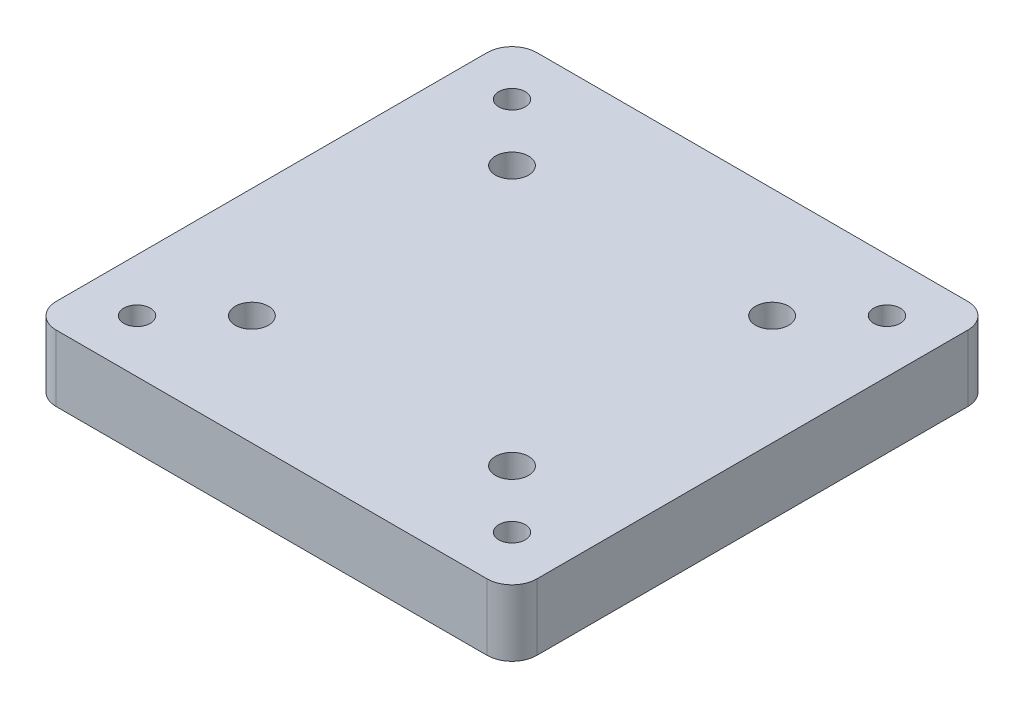
from build123d import *

# Parameters (mm, degrees)
SZKIC2_R                    = 1.6
SZKIC2_R_2                  = 1.598649761
SZKIC2_R_3                  = 1.598671199
SZKIC2_R_4                  = 2
DODANIE_WYCI_GNI_CIE1_DEPTH = 8
DODANIE_WYCI_GNI_CIE2_START = -2
SZKIC2_3_R                  = 6
SZKIC2_3_R_2                = 2
DODANIE_WYCI_GNI_CIE2_DEPTH = 2


with BuildPart() as part:
    # Szkic2 → Dodanie-wyci_gni_cie1 (new body)
    with BuildSketch(Plane(origin=(0, 0, 0), x_dir=(1, 0, 0), z_dir=(0, 1, 0))):
        with BuildLine():
            ThreePointArc((-79.341028527, -55.261863724), (-78.46234887, -57.383184068), (-76.341028527, -58.261863724))
            Line((-76.341028527, -58.261863724), (-24.341028527, -58.261863724))
            ThreePointArc((-24.341028527, -58.261863724), (-22.219708183, -57.383184068), (-21.341028527, -55.261863724))
            Line((-21.341028527, -55.261863724), (-21.341028527, -3.261863724))
            ThreePointArc((-21.341028527, -3.261863724), (-22.219708183, -1.140543381), (-24.341028527, -0.261863724))
            Line((-24.341028527, -0.261863724), (-76.341028527, -0.261863724))
            ThreePointArc((-76.341028527, -0.261863724), (-78.46234887, -1.140543381), (-79.341028527, -3.261863724))
            Line((-79.341028527, -3.261863724), (-79.341028527, -55.261863724))
        make_face()
        with Locations((-72.966028527, -51.886863724)):
            Circle(SZKIC2_R, mode=Mode.SUBTRACT)
        with Locations((-27.716028527, -51.886863724)):
            Circle(SZKIC2_R_2, mode=Mode.SUBTRACT)
        with Locations((-72.966028527, -6.636863724)):
            Circle(SZKIC2_R_3, mode=Mode.SUBTRACT)
        with Locations((-27.716028527, -6.636863724)):
            Circle(SZKIC2_R, mode=Mode.SUBTRACT)
        with Locations((-66.036028527, -44.956863724)):
            Circle(SZKIC2_R_4, mode=Mode.SUBTRACT)
        with Locations((-34.646028527, -44.956863724)):
            Circle(SZKIC2_R_4, mode=Mode.SUBTRACT)
        with Locations((-66.036028527, -13.566863724)):
            Circle(SZKIC2_R_4, mode=Mode.SUBTRACT)
        with Locations((-34.646028527, -13.566863724)):
            Circle(SZKIC2_R_4, mode=Mode.SUBTRACT)
    extrude(amount=DODANIE_WYCI_GNI_CIE1_DEPTH)

    # Szkic2_3 → Dodanie-wyci_gni_cie2 (add)
    # profile 1 of 4: a face of its own
    with BuildSketch(Plane(origin=(0, 0, 0), x_dir=(1, 0, 0), z_dir=(0, 1, 0)).offset(DODANIE_WYCI_GNI_CIE2_START)):
        with Locations((-66.036028527, -13.566863724)):
            Circle(SZKIC2_3_R)
        with Locations((-66.036028527, -13.566863724)):
            Circle(SZKIC2_3_R_2, mode=Mode.SUBTRACT)
    # profile 2 of 4: a face of its own
    with BuildSketch(Plane(origin=(0, 0, 0), x_dir=(1, 0, 0), z_dir=(0, 1, 0)).offset(DODANIE_WYCI_GNI_CIE2_START)):
        with Locations((-34.646028527, -13.566863724)):
            Circle(SZKIC2_3_R)
        with Locations((-34.646028527, -13.566863724)):
            Circle(SZKIC2_3_R_2, mode=Mode.SUBTRACT)
    # profile 3 of 4: a face of its own
    with BuildSketch(Plane(origin=(0, 0, 0), x_dir=(1, 0, 0), z_dir=(0, 1, 0)).offset(DODANIE_WYCI_GNI_CIE2_START)):
        with Locations((-66.036028527, -44.956863724)):
            Circle(SZKIC2_3_R)
        with Locations((-66.036028527, -44.956863724)):
            Circle(SZKIC2_3_R_2, mode=Mode.SUBTRACT)
    # profile 4 of 4: a face of its own
    with BuildSketch(Plane(origin=(0, 0, 0), x_dir=(1, 0, 0), z_dir=(0, 1, 0)).offset(DODANIE_WYCI_GNI_CIE2_START)):
        with Locations((-34.646028527, -44.956863724)):
            Circle(SZKIC2_3_R)
        with Locations((-34.646028527, -44.956863724)):
            Circle(SZKIC2_3_R_2, mode=Mode.SUBTRACT)
    extrude(amount=DODANIE_WYCI_GNI_CIE2_DEPTH)


solid = part.part
